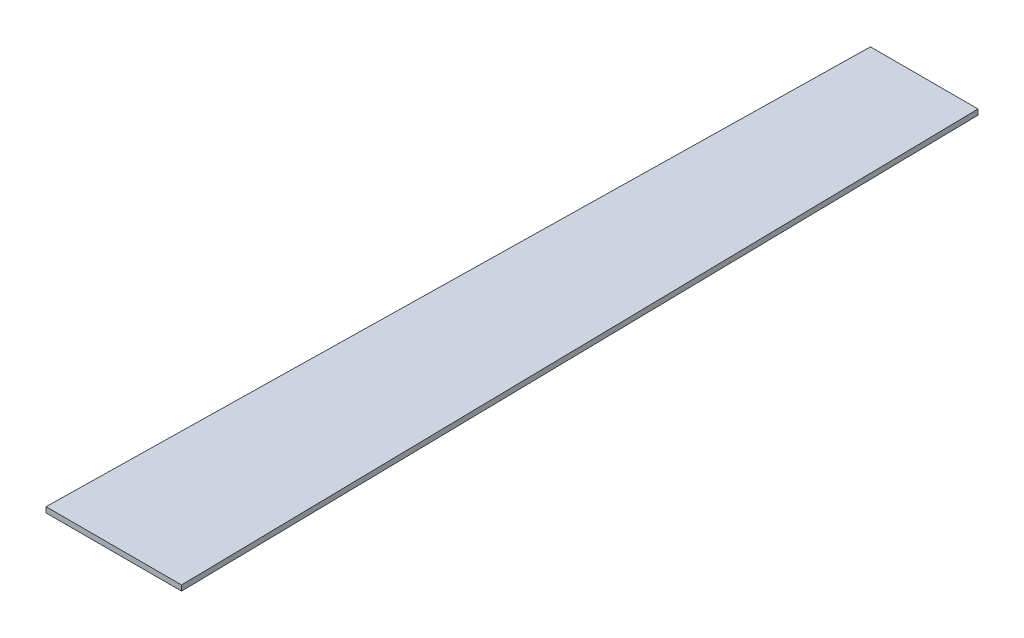
from build123d import *

# Parameters (mm, degrees)
BOSS_EXTRUDE1_DEPTH = 100
SKETCH2_W           = 1750
SKETCH2_H           = 125
CUT_EXTRUDE1_DEPTH  = 10
LPATTERN1_COUNT     = 30
LPATTERN1_PITCH     = 500


with BuildPart() as part:
    # Sketch1 → Boss-Extrude1 (new body)
    with BuildSketch(Plane(origin=(0, 0, 0), x_dir=(1, 0, 0), z_dir=(0, 1, 0))):
        Polygon((0, 0), (2000, 0), (2260, -15067.75696645), (-260, -15067.75696645), align=None)
    extrude(amount=BOSS_EXTRUDE1_DEPTH)

    # Sketch2 → Cut-Extrude1 (cut)
    with BuildSketch(Plane.XZ):
        with Locations((1000, 14759.321892241)):
            Rectangle(SKETCH2_W, SKETCH2_H)
    cut_extrude1 = extrude(amount=-CUT_EXTRUDE1_DEPTH, mode=Mode.SUBTRACT)

    # LPattern1: Cut-Extrude1 ×30
    with Locations(*[(0, 0, -i * LPATTERN1_PITCH) for i in range(1, LPATTERN1_COUNT)]):
        add(cut_extrude1, mode=Mode.SUBTRACT)


solid = part.part
